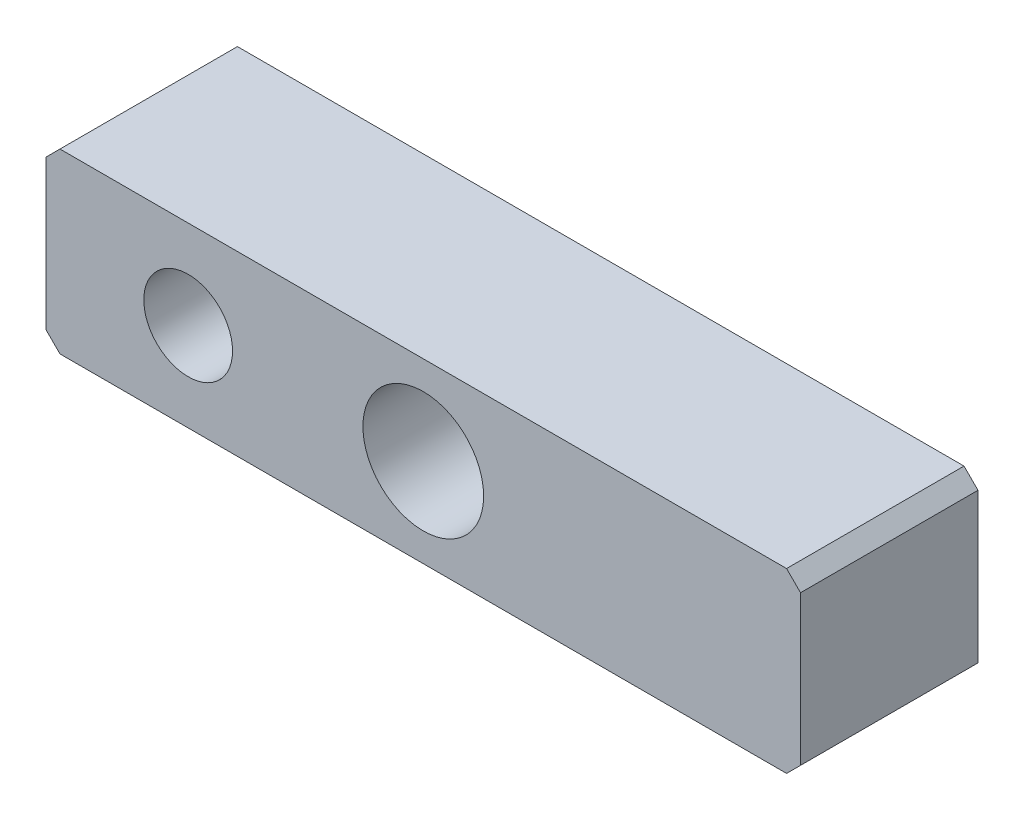
from build123d import *

# Parameters (mm, degrees)
SKETCH1_W           = 27
SKETCH1_H           = 6.35
SKETCH1_R           = 2.16
SKETCH1_R_2         = 1.5875
BOSS_EXTRUDE1_DEPTH = 6.35
CHAMFER1_SIZE       = 0.5


with BuildPart() as part:
    # Sketch1 → Boss-Extrude1 (new body)
    with BuildSketch(Plane.XY):
        with Locations((13.5, 3.175)):
            Rectangle(SKETCH1_W, SKETCH1_H)
        with Locations((13.5, 3.175)):
            Circle(SKETCH1_R, mode=Mode.SUBTRACT)
        with Locations((5.0875, 3.175)):
            Circle(SKETCH1_R_2, mode=Mode.SUBTRACT)
    extrude(amount=BOSS_EXTRUDE1_DEPTH)

    # Chamfer1
    chamfer1_edges = [part.edges().sort_by_distance(p)[0] for p in [
        (0, 6.35, 3.175),
        (27, 6.35, 3.175),
        (27, 0, 3.175),
        (0, 0, 3.175),
    ]]
    chamfer(chamfer1_edges, length=CHAMFER1_SIZE)


solid = part.part
